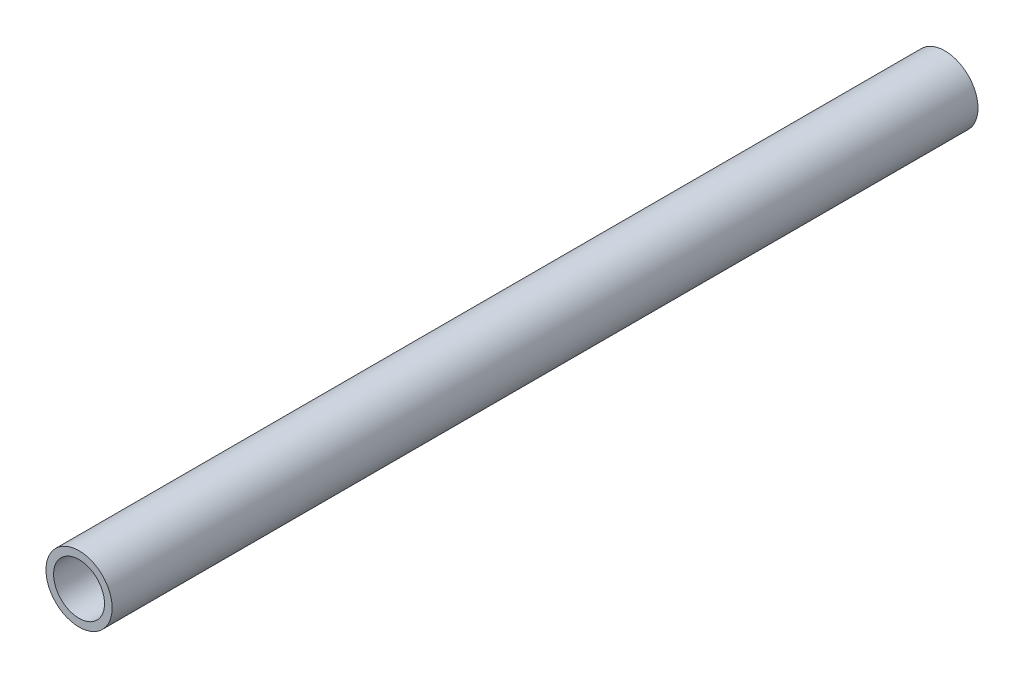
from build123d import *

# Parameters (mm, degrees)
CROQUIS1_R              = 6.5
CROQUIS1_R_2            = 5
SALIENTE_EXTRUIR1_DEPTH = 85


with BuildPart() as part:
    # Croquis1 → Saliente-Extruir1 (new body, symmetric)
    with BuildSketch(Plane.XY):
        Circle(CROQUIS1_R)
        Circle(CROQUIS1_R_2, mode=Mode.SUBTRACT)
    extrude(amount=SALIENTE_EXTRUIR1_DEPTH, both=True)


solid = part.part
